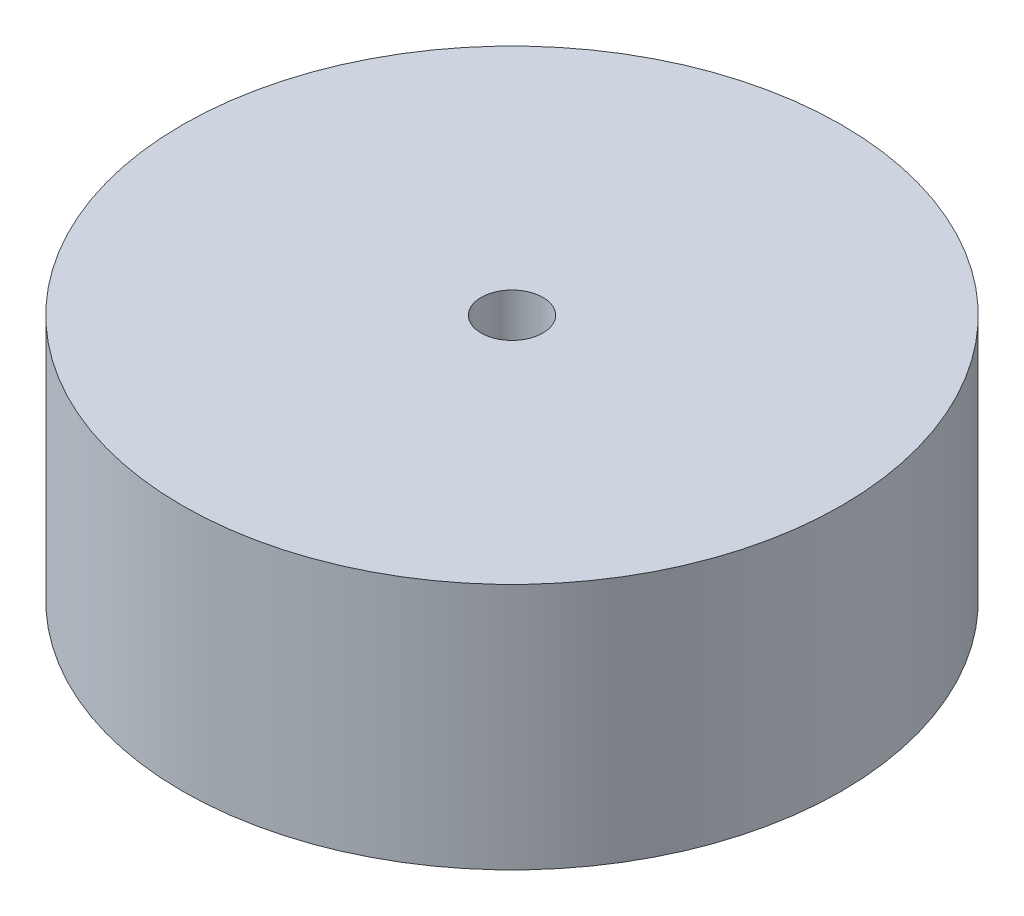
from build123d import *

# Parameters (mm, degrees)
SKETCH1_R           = 32
BOSS_EXTRUDE1_DEPTH = 24
SKETCH2_R           = 3
CUT_EXTRUDE1_DEPTH  = 24


with BuildPart() as part:
    # Sketch1 → Boss-Extrude1 (new body)
    with BuildSketch(Plane(origin=(0, 0, 0), x_dir=(1, 0, 0), z_dir=(0, 1, 0))):
        Circle(SKETCH1_R)
    extrude(amount=BOSS_EXTRUDE1_DEPTH)

    # Sketch2 → Cut-Extrude1 (cut)
    with BuildSketch(Plane(origin=(0, 24, 0), x_dir=(1, 0, 0), z_dir=(0, 1, 0))):
        Circle(SKETCH2_R)
    extrude(amount=-CUT_EXTRUDE1_DEPTH, mode=Mode.SUBTRACT)


solid = part.part
